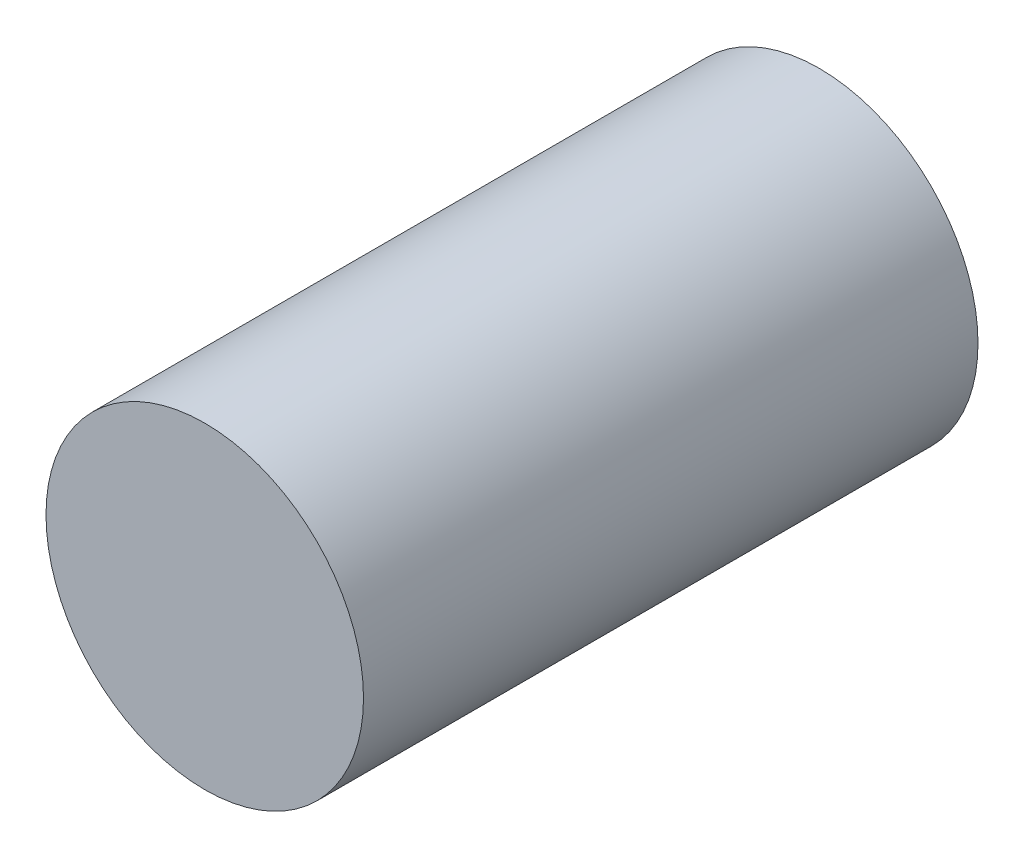
from build123d import *

# Parameters (mm, degrees)
CROQUIS1_R              = 1.55
SALIENTE_EXTRUIR1_DEPTH = 6


with BuildPart() as part:
    # Croquis1 → Saliente-Extruir1 (new body)
    with BuildSketch(Plane.XY):
        Circle(CROQUIS1_R)
    extrude(amount=SALIENTE_EXTRUIR1_DEPTH)


solid = part.part
